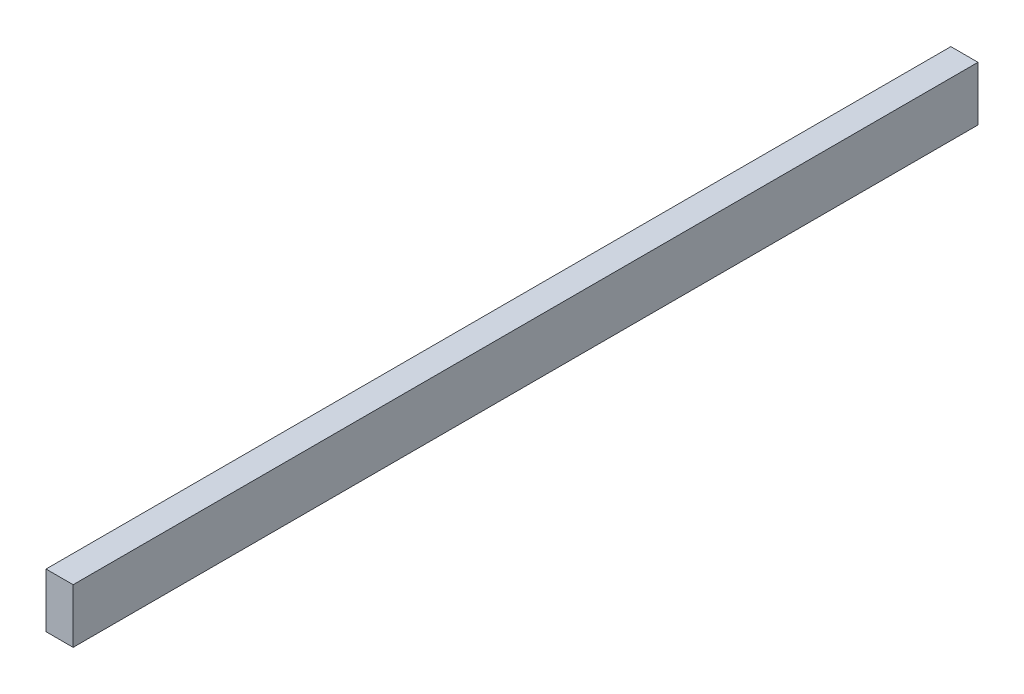
from build123d import *

# Parameters (mm, degrees)
SKETCH_2_W      = 3
SKETCH_2_H      = 6
EXTRUDE_1_DEPTH = 100


with BuildPart() as part:
    # 草图2 → 凸台-拉伸1 (new body)
    with BuildSketch(Plane.XY):
        with Locations((-1.5, 0.204721125)):
            Rectangle(SKETCH_2_W, SKETCH_2_H)
    extrude(amount=EXTRUDE_1_DEPTH)


solid = part.part
